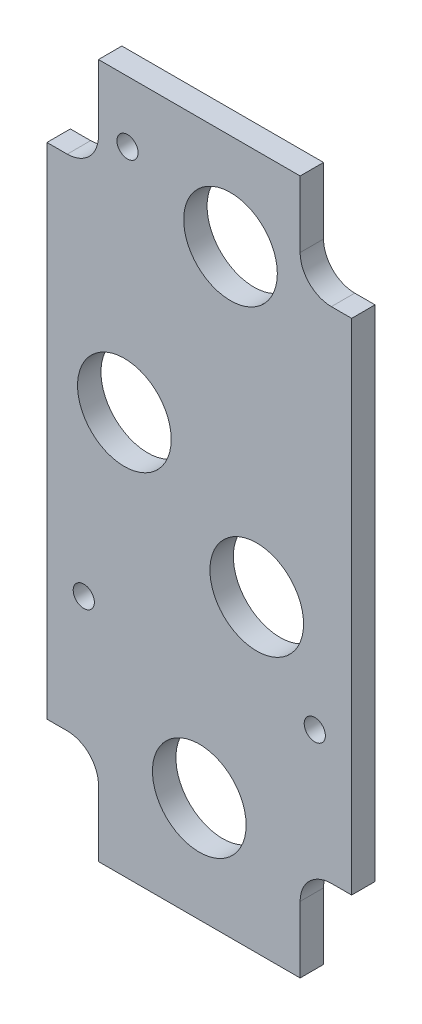
from build123d import *

# Parameters (mm, degrees)
BOSS_EXTRUDE1_DEPTH             = 4.7625
F_6_CLEARANCE_HOLE1_D           = 4.3053
F_6_CLEARANCE_HOLE1_DEPTH       = 4.7625
F_3_4_0_75_DIAMETER_HOLE1_D     = 19.05
F_3_4_0_75_DIAMETER_HOLE1_DEPTH = 4.7625


with BuildPart() as part:
    # Sketch1 → Boss-Extrude1 (new body)
    with BuildSketch(Plane.XY.offset(-5.842)):
        with BuildLine():
            Line((-20.5105, -128.5875), (-20.5105, -142.08125))
            Line((-20.5105, -142.08125), (20.5105, -142.08125))
            Line((20.5105, -142.08125), (20.5105, -128.5875))
            ThreePointArc((20.5105, -128.5875), (22.370371939, -124.097371939), (26.8605, -122.2375))
            Line((26.8605, -122.2375), (30.988, -122.2375))
            Line((30.988, -122.2375), (30.988, -20.6375))
            Line((30.988, -20.6375), (26.8605, -20.6375))
            ThreePointArc((26.8605, -20.6375), (22.370371939, -18.777628061), (20.5105, -14.2875))
            Line((20.5105, -14.2875), (20.5105, -0.79375))
            Line((20.5105, -0.79375), (-20.5105, -0.79375))
            Line((-20.5105, -0.79375), (-20.5105, -14.2875))
            ThreePointArc((-20.5105, -14.2875), (-22.370371939, -18.777628061), (-26.8605, -20.6375))
            Line((-26.8605, -20.6375), (-30.988, -20.6375))
            Line((-30.988, -20.6375), (-30.988, -122.2375))
            Line((-30.988, -122.2375), (-26.8605, -122.2375))
            ThreePointArc((-26.8605, -122.2375), (-22.370371939, -124.097371939), (-20.5105, -128.5875))
        make_face()
    extrude(amount=BOSS_EXTRUDE1_DEPTH)

    # #6 Clearance Hole1
    with Locations(Plane.XY.offset(-1.0795)):
        with Locations((-14.605, -13.208), (-23.495, -96.8375), (23.495, -96.8375)):
            Hole(F_6_CLEARANCE_HOLE1_D / 2, depth=F_6_CLEARANCE_HOLE1_DEPTH)

    # 3/4 (0.75) Diameter Hole1
    with Locations(Plane.XY.offset(-1.0795)):
        with Locations((-15.24, -60.325), (6.35, -20.32), (11.684, -79.375), (0, -120.65)):
            Hole(F_3_4_0_75_DIAMETER_HOLE1_D / 2, depth=F_3_4_0_75_DIAMETER_HOLE1_DEPTH)


solid = part.part
